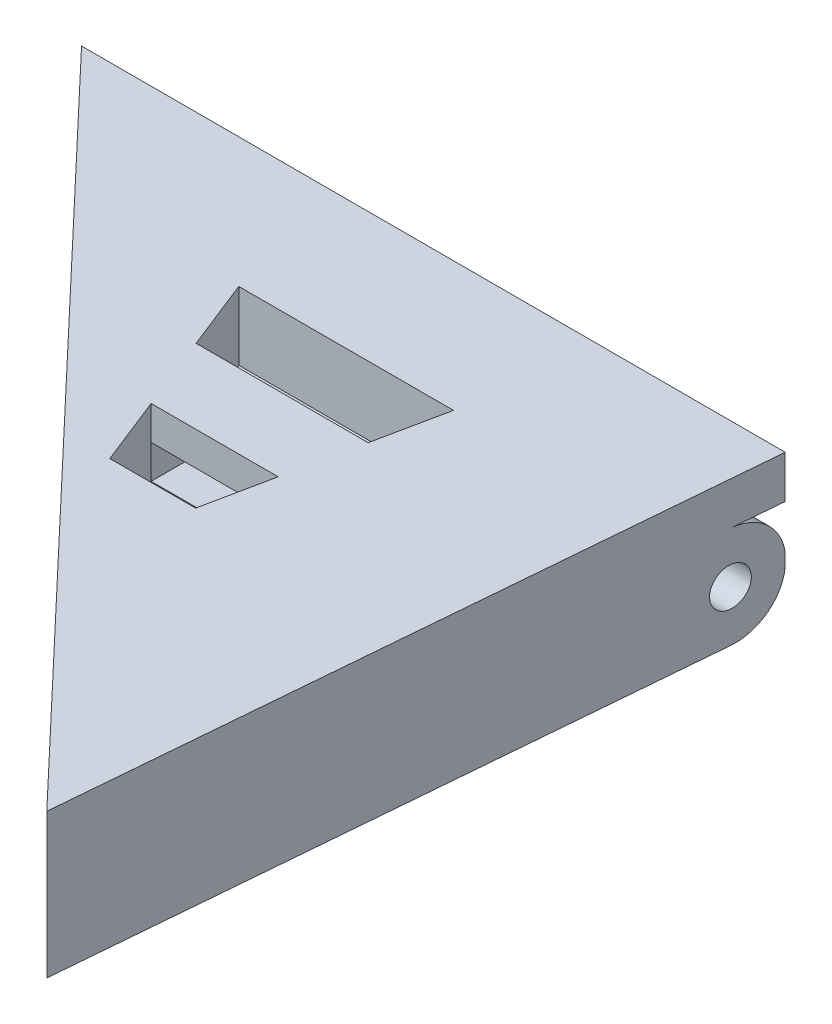
from build123d import *

# Parameters (mm, degrees)
BOSS_EXTRUDE1_DEPTH     = 15.24
CUT_EXTRUDE1_DEPTH      = 2.54
SKETCH3_W               = 34.486175175
SKETCH3_H               = 6.644984791
CUT_EXTRUDE2_DEPTH      = 34.544
CUT_EXTRUDE2_DEPTH_BACK = 19.812
CUT_EXTRUDE3_DEPTH      = 4.064
SKETCH5_W               = 7.563523275
SKETCH5_H               = 2.007464402
CUT_EXTRUDE4_DEPTH      = 6.604
BOSS_EXTRUDE2_DEPTH     = 2.54


with BuildPart() as part:
    # Sketch1 → Boss-Extrude1 (new body)
    with BuildSketch(Plane(origin=(0, 0, 0), x_dir=(1, 0, 0), z_dir=(0, 1, 0))):
        Polygon((0, 0), (21.138647769, 0), (21.138647769, 6.005297662), (28.985570047, 6.005297662), (25.514226291, -34.486175175), (-12.907838022, 6.005297662), (0, 6.005297662), align=None)
    extrude(amount=BOSS_EXTRUDE1_DEPTH)

    # Sketch2 → Cut-Extrude1 (cut)
    with BuildSketch(Plane(origin=(0, 15.24, 0), x_dir=(1, 0, 0), z_dir=(0, 1, 0))):
        Polygon((21.138647769, 0), (28.470734427, 0), (28.985570047, 6.005297662), (21.138647769, 6.005297662), align=None)
        Polygon((0, 0), (-7.209454713, 0), (-12.907838022, 6.005297662), (0, 6.005297662), align=None)
    extrude(amount=-CUT_EXTRUDE1_DEPTH, mode=Mode.SUBTRACT)

    # Sketch3 → Cut-Extrude2 (cut, two sides)
    with BuildSketch(Plane(origin=(0, 0, 0), x_dir=(0, 0, -1), z_dir=(1, 0, 0))) as cut_extrude2_sk:
        with BuildLine():
            Line((6.005297662, 12.7), (3.002648831, 12.7))
            ThreePointArc((3.002648831, 12.7), (5.001853121, 11.946032476), (6.005297662, 10.05966457))
            Line((6.005297662, 10.05966457), (6.005297662, 12.7))
        make_face()
        with BuildLine():
            ThreePointArc((4.147717946, 9.672492396), (3.443027426, 10.729492855), (2.196307404, 10.485509481))
            Line((2.196307404, 10.485509481), (3.808990258, 8.85947531))
            ThreePointArc((3.808990258, 8.85947531), (4.059649291, 9.2321138), (4.147717946, 9.672492396))
        make_face()
        with BuildLine():
            Line((3.808990258, 8.85947531), (2.196307404, 10.485509481))
            ThreePointArc((2.196307404, 10.485509481), (2.189631745, 8.866150969), (3.808990258, 8.85947531))
        make_face()
        with BuildLine():
            ThreePointArc((5.134576738, 7.522914369), (4.155458111, 6.873057978), (3.002648831, 6.644984791))
            Line((3.002648831, 6.644984791), (6.005297662, 6.644984791))
            Line((6.005297662, 6.644984791), (5.134576738, 7.522914369))
        make_face()
        with BuildLine():
            Line((6.005297662, 6.644984791), (6.005297662, 9.285320221))
            ThreePointArc((6.005297662, 9.285320221), (5.716960561, 8.331480044), (5.134576738, 7.522914369))
            Line((5.134576738, 7.522914369), (6.005297662, 6.644984791))
        make_face()
        Polygon((3.002648831, 6.644984791), (0, 6.644984791), (0, 0), (6.005297662, 0), (6.005297662, 6.644984791), align=None)
        with Locations((-17.243087587, 3.322492396)):
            Rectangle(SKETCH3_W, SKETCH3_H)
    extrude(amount=CUT_EXTRUDE2_DEPTH, mode=Mode.SUBTRACT)
    extrude(cut_extrude2_sk.sketch, amount=-CUT_EXTRUDE2_DEPTH_BACK, mode=Mode.SUBTRACT)

    # Sketch4 → Cut-Extrude3 (cut)
    with BuildSketch(Plane(origin=(0, 15.24, 0), x_dir=(1, 0, 0), z_dir=(0, 1, 0))):
        Polygon((10.569323885, -5.914326858), (10.569323885, -1.709556921), (4.167807975, -1.709556921), (5.834265352, -5.914326858), align=None)
        Polygon((16.948973736, -1.709556921), (10.569323885, -1.709556921), (10.569323885, -5.914326858), (16.077118552, -5.914326858), align=None)
        Polygon((10.569323885, -14.423980302), (10.569323885, -10.352695125), (7.593303694, -10.352695125), (9.206857662, -14.423980302), align=None)
        Polygon((15.156826969, -10.352695125), (10.569323885, -10.352695125), (10.569323885, -14.423980302), (14.312649728, -14.423980302), align=None)
    extrude(amount=-CUT_EXTRUDE3_DEPTH, mode=Mode.SUBTRACT)

    # Sketch5 → Cut-Extrude4 (cut)
    with BuildSketch(Plane.XY.offset(10.352695125)):
        with Locations((11.375065332, 12.228803396)):
            Rectangle(SKETCH5_W, SKETCH5_H)
    extrude(amount=-CUT_EXTRUDE4_DEPTH, mode=Mode.SUBTRACT)

    # Sketch6 → Boss-Extrude2 (add)
    with BuildSketch(Plane(origin=(0, 15.24, 0), x_dir=(1, 0, 0), z_dir=(0, 1, 0))):
        Polygon((28.470734427, 0), (28.985570047, 6.005297662), (-12.907838022, 6.005297662), (-7.209454713, 0), align=None)
    extrude(amount=-BOSS_EXTRUDE2_DEPTH)


solid = part.part
